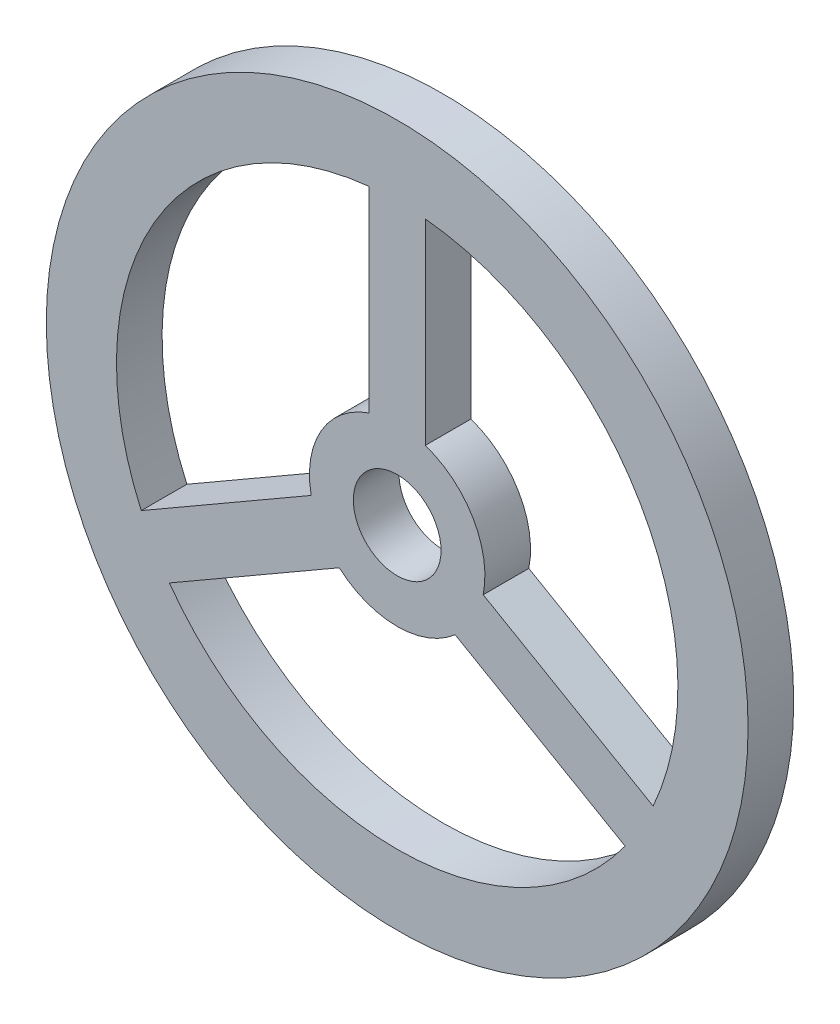
from build123d import *

# Parameters (mm, degrees)
ESQUISSE1_R               = 10
BASE_DEPTH                = 1.3
HOLES_DEPTH               = 2.3
ESQUISSE3_R               = 1.25
HOLE_TO_STIRRER_BAR_DEPTH = 2.3


with BuildPart() as part:
    # Esquisse1 → base (new body)
    with BuildSketch(Plane.XY):
        Circle(ESQUISSE1_R)
    extrude(amount=BASE_DEPTH)

    # Esquisse2 → holes (cut, through all)
    with BuildSketch(Plane.XY.offset(1.3)):
        with BuildLine():
            Line((-7.293475176, -3.287129425), (-2.45121915, -0.491451605))
            ThreePointArc((-2.45121915, -0.491451605), (-2.165063509, 1.25), (-0.8, 2.368543856))
            Line((-0.8, 2.368543856), (-0.8, 7.959899497))
            ThreePointArc((-0.8, 7.959899497), (-6.92820323, 4), (-7.293475176, -3.287129425))
        make_face()
        with BuildLine():
            Line((-6.493475176, -4.672770071), (-1.65121915, -1.877092251))
            ThreePointArc((-1.65121915, -1.877092251), (0, -2.5), (1.65121915, -1.877092251))
            Line((1.65121915, -1.877092251), (6.493475176, -4.672770071))
            ThreePointArc((6.493475176, -4.672770071), (0, -8), (-6.493475176, -4.672770071))
        make_face()
        with BuildLine():
            Line((2.45121915, -0.491451605), (7.293475176, -3.287129425))
            ThreePointArc((7.293475176, -3.287129425), (6.92820323, 4), (0.8, 7.959899497))
            Line((0.8, 7.959899497), (0.8, 2.368543856))
            ThreePointArc((0.8, 2.368543856), (2.165063509, 1.25), (2.45121915, -0.491451605))
        make_face()
    extrude(amount=-HOLES_DEPTH, mode=Mode.SUBTRACT)

    # Esquisse3 → hole_to_stirrer_bar (cut, through all)
    with BuildSketch(Plane.XY.offset(1.3)):
        Circle(ESQUISSE3_R)
    extrude(amount=-HOLE_TO_STIRRER_BAR_DEPTH, mode=Mode.SUBTRACT)


solid = part.part
